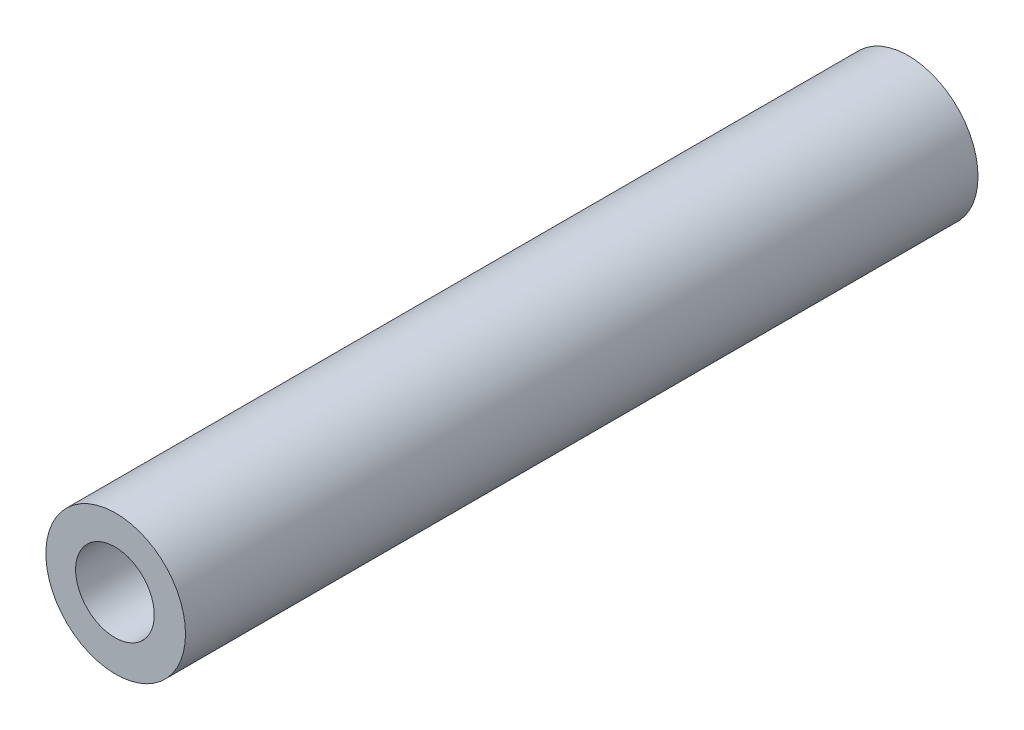
from build123d import *

# Parameters (mm, degrees)
SKETCH_1_R          = 5.815
EXTRUDE_2_DEPTH     = 66
SKETCH_5_R          = 3.275
CUT_EXTRUDE_3_DEPTH = 67


with BuildPart() as part:
    # 草图1 → 凸台-拉伸2 (new body)
    with BuildSketch(Plane.XY):
        with Locations((0.046458344, -0.064930956)):
            Circle(SKETCH_1_R)
    extrude(amount=EXTRUDE_2_DEPTH)

    # 草图5 → 切除-拉伸3 (cut, through all)
    with BuildSketch(Plane.XY.offset(66)):
        with Locations((-0.01692302, 0.006373079)):
            Circle(SKETCH_5_R)
    extrude(amount=-CUT_EXTRUDE_3_DEPTH, mode=Mode.SUBTRACT)


solid = part.part
